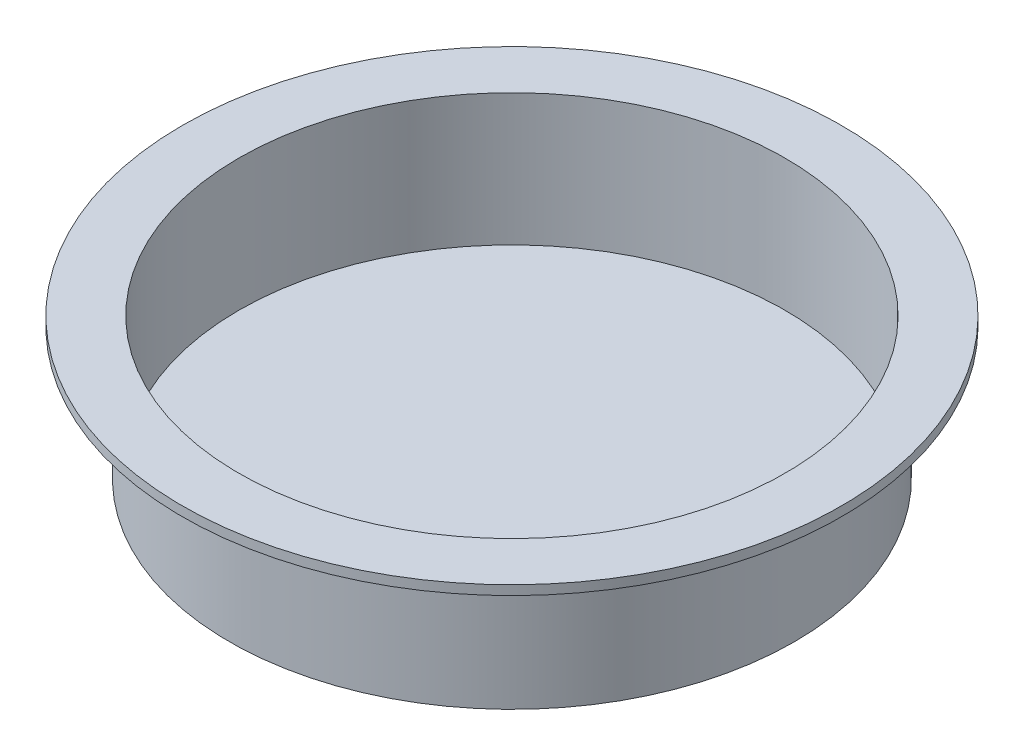
from build123d import *

# Parameters (mm, degrees)
SKETCH4_R          = 36.83
CUT_EXTRUDE1_DEPTH = 17.78


with BuildPart() as part:
    # Sketch3 → Revolve1 (revolve)
    with BuildSketch(Plane.XY):
        Polygon((0, 0), (38.1, 0), (38.1, 17.78), (44.45, 17.78), (44.45, 19.05), (0, 19.05), align=None)
    revolve(axis=Axis((0, 19.05, 0), (0, -1, 0)))

    # Sketch4 → Cut-Extrude1 (cut)
    with BuildSketch(Plane(origin=(0, 19.05, 0), x_dir=(1, 0, 0), z_dir=(0, 1, 0))):
        Circle(SKETCH4_R)
    extrude(amount=-CUT_EXTRUDE1_DEPTH, mode=Mode.SUBTRACT)


solid = part.part
